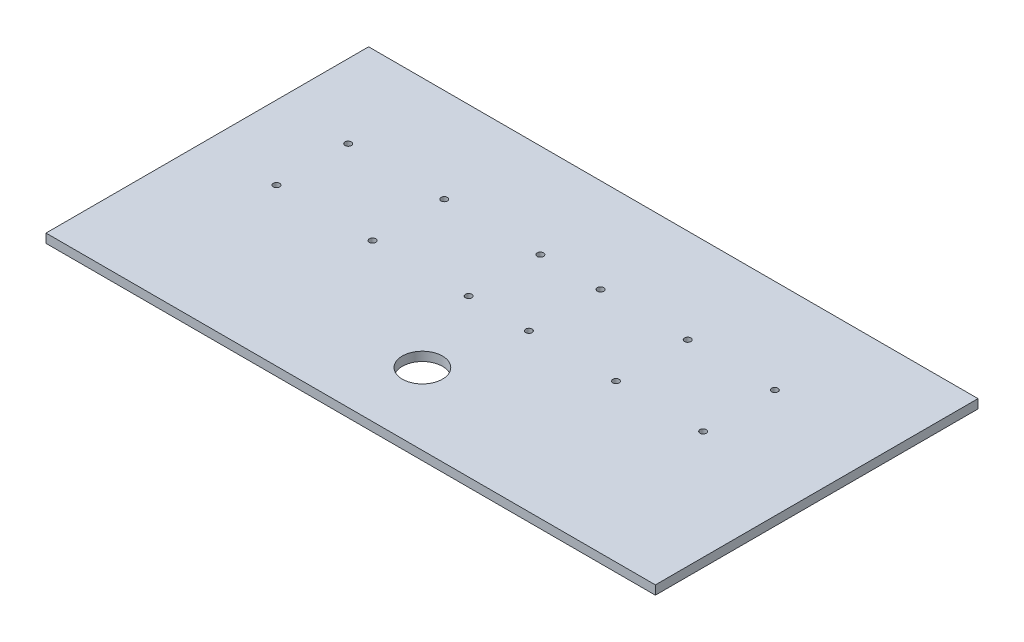
from build123d import *

# Parameters (mm, degrees)
SKETCH2_W           = 431.8
SKETCH2_H           = 228.6
BOSS_EXTRUDE1_DEPTH = 6.35
SKETCH4_R           = 14.224
CUT_EXTRUDE1_DEPTH  = 6.35
SKETCH5_R           = 2.24967597
CUT_EXTRUDE2_DEPTH  = 25.4
SKETCH6_R           = 2.24967597
SKETCH6_R_2         = 2.249660739
SKETCH6_R_3         = 2.249660728
CUT_EXTRUDE3_DEPTH  = 25.4
SKETCH7_R           = 2.24967597
SKETCH7_R_2         = 2.249660728
CUT_EXTRUDE4_DEPTH  = 25.4


with BuildPart() as part:
    # Sketch2 → Boss-Extrude1 (new body)
    with BuildSketch(Plane(origin=(0, 0, 0), x_dir=(1, 0, 0), z_dir=(0, 1, 0))):
        with Locations((215.9, 114.3)):
            Rectangle(SKETCH2_W, SKETCH2_H)
    extrude(amount=BOSS_EXTRUDE1_DEPTH)

    # Sketch4 → Cut-Extrude1 (cut)
    with BuildSketch(Plane(origin=(0, 6.35, 0), x_dir=(1, 0, 0), z_dir=(0, 1, 0))):
        with Locations((215.9, 50.8)):
            Circle(SKETCH4_R)
    extrude(amount=-CUT_EXTRUDE1_DEPTH, mode=Mode.SUBTRACT)

    # Sketch5 → Cut-Extrude2 (cut)
    with BuildSketch(Plane(origin=(0, 0, 0), x_dir=(-1, 0, 0), z_dir=(0, -1, 0))):
        with Locations((-52.232812268, 111.081338493)):
            Circle(SKETCH5_R)
        with Locations((-52.232812268, 161.881338493)):
            Circle(SKETCH5_R)
    extrude(amount=-CUT_EXTRUDE2_DEPTH, mode=Mode.SUBTRACT)

    # Sketch6 → Cut-Extrude3 (cut)
    with BuildSketch(Plane(origin=(0, 0, 0), x_dir=(-1, 0, 0), z_dir=(0, -1, 0))):
        with Locations((-120.314890813, 111.081338493)):
            Circle(SKETCH6_R)
        with Locations((-120.314890813, 161.881338493)):
            Circle(SKETCH6_R)
        with Locations((-188.396969359, 111.081338493)):
            Circle(SKETCH6_R_2)
        with Locations((-188.396969359, 161.881338493)):
            Circle(SKETCH6_R_3)
    extrude(amount=-CUT_EXTRUDE3_DEPTH, mode=Mode.SUBTRACT)

    # Sketch7 → Cut-Extrude4 (cut)
    with BuildSketch(Plane(origin=(0, 0, 0), x_dir=(-1, 0, 0), z_dir=(0, -1, 0))):
        with Locations((-231.079047904, 111.081338493)):
            Circle(SKETCH7_R)
        with Locations((-231.079047904, 161.881338493)):
            Circle(SKETCH7_R_2)
        with Locations((-292.811126449, 111.081338493)):
            Circle(SKETCH7_R_2)
        with Locations((-292.811126449, 161.881338493)):
            Circle(SKETCH7_R_2)
        with Locations((-354.543204994, 111.081338493)):
            Circle(SKETCH7_R_2)
        with Locations((-354.543204994, 161.881338493)):
            Circle(SKETCH7_R_2)
    extrude(amount=-CUT_EXTRUDE4_DEPTH, mode=Mode.SUBTRACT)


solid = part.part
